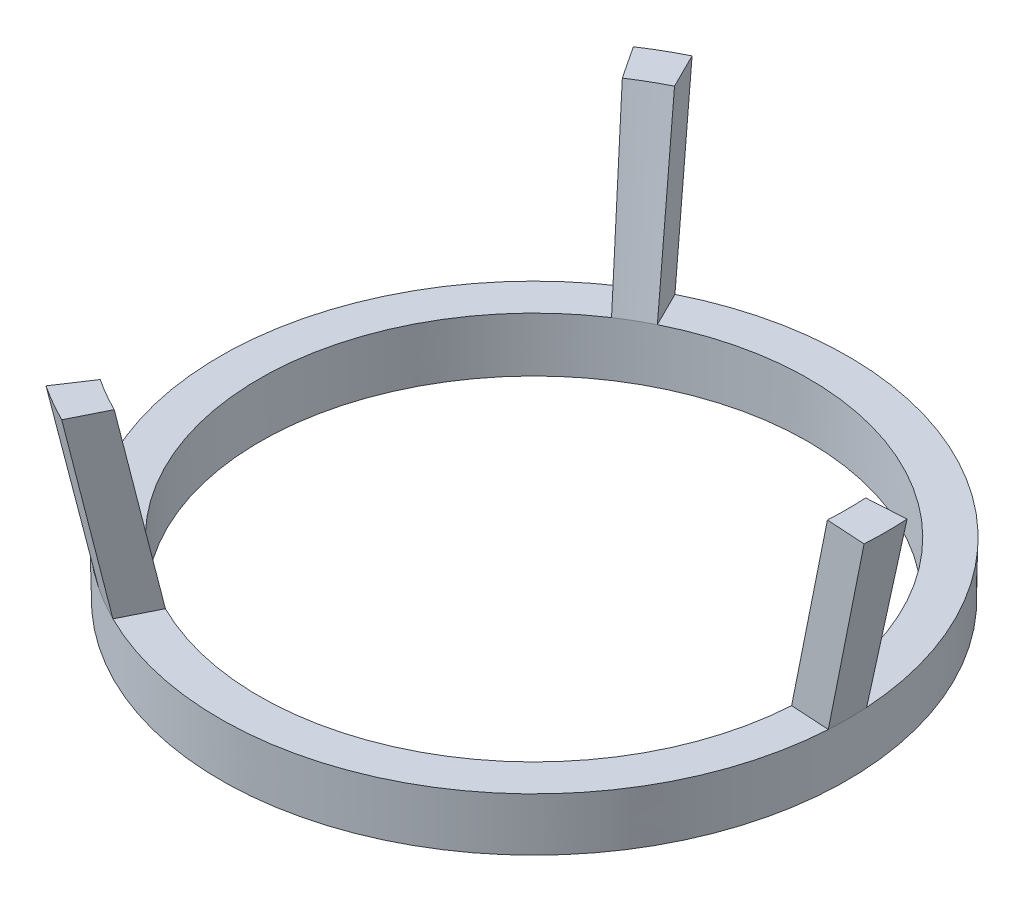
from build123d import *

# Parameters (mm, degrees)
REVOLVE2_ANGLE    = 7
CIRPATTERN1_COUNT = 3


with BuildPart() as part:
    # Sketch1 → Revolve1 (revolve)
    with BuildSketch(Plane.XY, mode=Mode.PRIVATE) as revolve1_sk:
        Polygon((14, 0), (14.049784483, 2.75), (16.049784483, 2.75), (16, 0), align=None)
    revolve(revolve1_sk.sketch.rotate(Axis((0, 0, 0), (0, 1, 0)), 90), axis=Axis((0, 0, 0), (0, 1, 0)))  # turned: the seam where the file's is

    # Sketch2 → Revolve2 (revolve, symmetric)
    with BuildSketch(Plane.XY) as revolve2_sk:
        Polygon((14.049784483, 2.75), (16, 12), (18, 12), (16.049784483, 2.75), align=None)
    revolve2 = revolve(axis=Axis((0, 0, 0), (0, 1, 0)), revolution_arc=REVOLVE2_ANGLE / 2)
    revolve2 = revolve2 + revolve(revolve2_sk.sketch, axis=Axis((0, 0, 0), (0, -1, 0)), revolution_arc=REVOLVE2_ANGLE / 2)

    # CirPattern1: Revolve2 ×3 about axis
    cirpattern1_axis = Axis((0, 0, 0), (0, 1, 0))
    for i in range(1, CIRPATTERN1_COUNT):
        add(revolve2.rotate(cirpattern1_axis, i * 360 / CIRPATTERN1_COUNT))


solid = part.part
